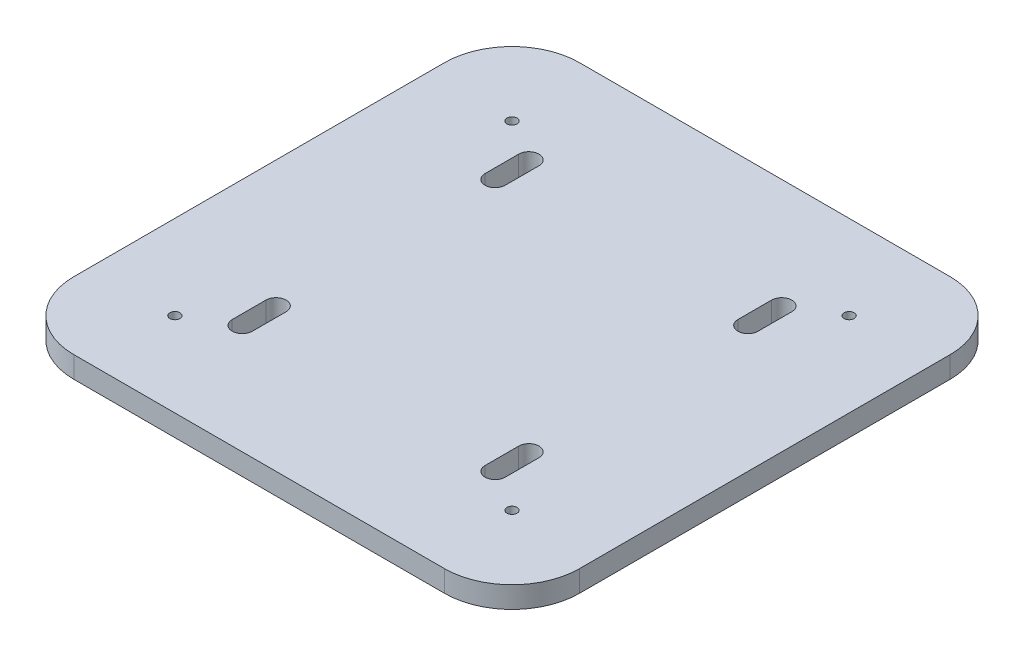
from build123d import *

# Parameters (mm, degrees)
SKETCH1_R           = 1.5
BOSS_EXTRUDE1_DEPTH = 6.35
CUT_EXTRUDE1_DEPTH  = 10


with BuildPart() as part:
    # Sketch1 → Boss-Extrude1 (new body)
    with BuildSketch(Plane(origin=(0, 0, 0), x_dir=(1, 0, 0), z_dir=(0, 1, 0))):
        with BuildLine():
            Line((-55, 75), (55, 75))
            ThreePointArc((55, 75), (69.142135624, 69.142135624), (75, 55))
            Line((75, 55), (75, -55))
            ThreePointArc((75, -55), (69.142135624, -69.142135624), (55, -75))
            Line((55, -75), (-55, -75))
            ThreePointArc((-55, -75), (-69.142135624, -69.142135624), (-75, -55))
            Line((-75, -55), (-75, 55))
            ThreePointArc((-75, 55), (-69.142135624, 69.142135624), (-55, 75))
        make_face()
        with Locations((50, 50)):
            Circle(SKETCH1_R, mode=Mode.SUBTRACT)
        with Locations((50, -50)):
            Circle(SKETCH1_R, mode=Mode.SUBTRACT)
        with Locations((-50, -50)):
            Circle(SKETCH1_R, mode=Mode.SUBTRACT)
        with Locations((-50, 50)):
            Circle(SKETCH1_R, mode=Mode.SUBTRACT)
    extrude(amount=BOSS_EXTRUDE1_DEPTH)

    # Sketch2 → Cut-Extrude1 (cut)
    with BuildSketch(Plane(origin=(0, 6.35, 0), x_dir=(1, 0, 0), z_dir=(0, 1, 0))):
        with BuildLine():
            Line((40.5, 42.5), (40.5, 32.5))
            ThreePointArc((40.5, 32.5), (37.5, 29.5), (34.5, 32.5))
            Line((34.5, 32.5), (34.5, 42.5))
            ThreePointArc((34.5, 42.5), (37.5, 45.5), (40.5, 42.5))
        make_face()
        with BuildLine():
            Line((-34.5, 42.5), (-34.5, 32.5))
            ThreePointArc((-34.5, 32.5), (-37.5, 29.5), (-40.5, 32.5))
            Line((-40.5, 32.5), (-40.5, 42.5))
            ThreePointArc((-40.5, 42.5), (-37.5, 45.5), (-34.5, 42.5))
        make_face()
        with BuildLine():
            Line((40.5, -42.5), (40.5, -32.5))
            ThreePointArc((40.5, -32.5), (37.5, -29.5), (34.5, -32.5))
            Line((34.5, -32.5), (34.5, -42.5))
            ThreePointArc((34.5, -42.5), (37.5, -45.5), (40.5, -42.5))
        make_face()
        with BuildLine():
            Line((-34.5, -42.5), (-34.5, -32.5))
            ThreePointArc((-34.5, -32.5), (-37.5, -29.5), (-40.5, -32.5))
            Line((-40.5, -32.5), (-40.5, -42.5))
            ThreePointArc((-40.5, -42.5), (-37.5, -45.5), (-34.5, -42.5))
        make_face()
    extrude(amount=-CUT_EXTRUDE1_DEPTH, mode=Mode.SUBTRACT)


solid = part.part
